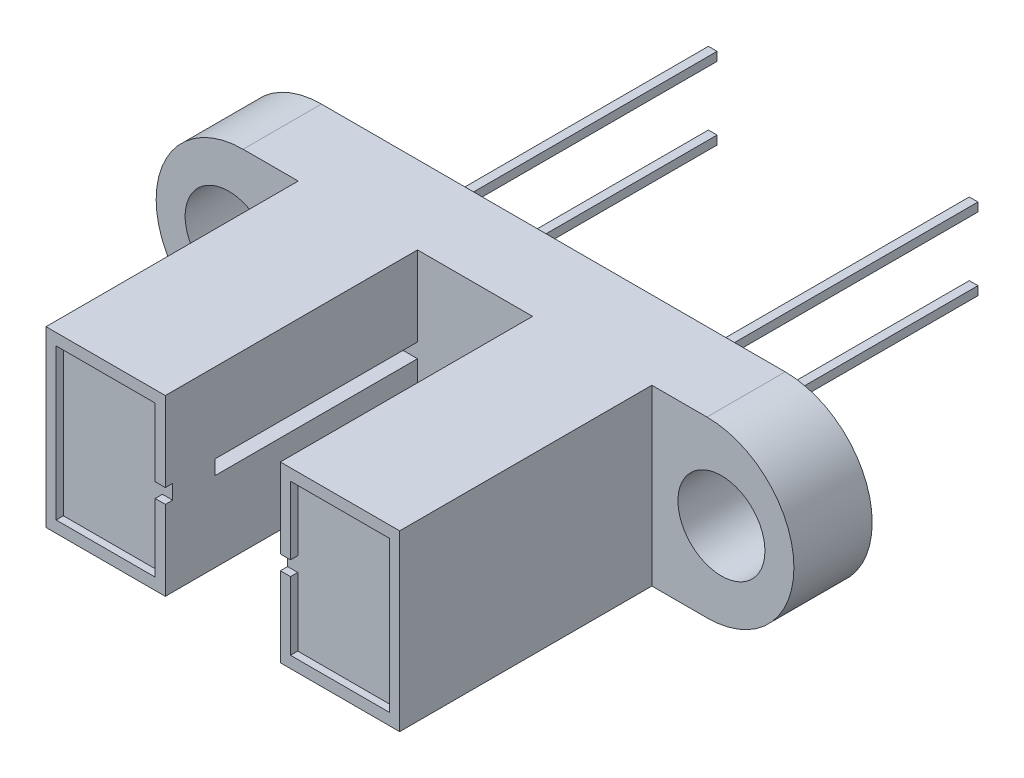
from build123d import *

# Parameters (mm, degrees)
BOSS_EXTRUDE1_DEPTH  = 2.7
SKETCH2_R            = 1.5
CUT_EXTRUDE1_DEPTH   = 3.7
SKETCH3_W            = 4.115625
SKETCH3_H            = 6
BOSS_EXTRUDE2_DEPTH  = 8.7
SKETCH4_W            = 12
SKETCH4_H            = 3
CUT_EXTRUDE2_DEPTH   = 2
CUT_EXTRUDE3_DEPTH   = 0.25
SKETCH6_W            = 0.3
SKETCH6_H            = 0.3
BOSS_EXTRUDE3_DEPTH  = 12
LPATTERN1_COUNT      = 2
LPATTERN1_PITCH      = 2.5
LPATTERN1_COUNT_DIR2 = 2
LPATTERN1_PITCH_DIR2 = 9
SKETCH7_W            = 6.98
SKETCH7_H            = 0.5
CUT_EXTRUDE4_DEPTH   = 1


with BuildPart() as part:
    # Sketch1 → Boss-Extrude1 (new body)
    with BuildSketch(Plane.XY):
        with BuildLine():
            Line((-8, 3), (8, 3))
            ThreePointArc((8, 3), (11, 0), (8, -3))
            Line((8, -3), (-8, -3))
            ThreePointArc((-8, -3), (-11, 0), (-8, 3))
        make_face()
    extrude(amount=BOSS_EXTRUDE1_DEPTH)

    # Sketch2 → Cut-Extrude1 (cut, through all)
    with BuildSketch(Plane.XY.offset(2.7)):
        with Locations((-8.5, 0)):
            Circle(SKETCH2_R)
        with Locations((8.5, 0)):
            Circle(SKETCH2_R)
    extrude(amount=-CUT_EXTRUDE1_DEPTH, mode=Mode.SUBTRACT)

    # Sketch3 → Boss-Extrude2 (add)
    with BuildSketch(Plane.XY.offset(2.7)):
        with Locations((-4.0421875, 0)):
            Rectangle(SKETCH3_W, SKETCH3_H)
        with Locations((4.0421875, 0)):
            Rectangle(SKETCH3_W, SKETCH3_H)
    extrude(amount=BOSS_EXTRUDE2_DEPTH)

    # Sketch4 → Cut-Extrude2 (cut)
    with BuildSketch(Plane(origin=(0, 0, 0), x_dir=(-1, 0, 0), z_dir=(0, 0, -1))):
        Rectangle(SKETCH4_W, SKETCH4_H)
    extrude(amount=-CUT_EXTRUDE2_DEPTH, mode=Mode.SUBTRACT)

    # Sketch5 → Cut-Extrude3 (cut)
    with BuildSketch(Plane.XY.offset(11.4)):
        Polygon((-2.334375, 0.25), (-1.984375, 0.25), (-1.984375, -0.25), (-2.334375, -0.25), (-2.334375, -2.6), (-5.75, -2.6), (-5.75, 2.6), (-2.334375, 2.6), align=None)
    cut_extrude3 = extrude(amount=-CUT_EXTRUDE3_DEPTH, mode=Mode.SUBTRACT)

    # Mirror1: Cut-Extrude3 across plane
    add(cut_extrude3.mirror(Plane(origin=(0, 0, 0), x_dir=(0, 0, 1), z_dir=(1, 0, 0))), mode=Mode.SUBTRACT)

    # Sketch6 → Boss-Extrude3 (add)
    with BuildSketch(Plane(origin=(0, 0, 2), x_dir=(-1, 0, 0), z_dir=(0, 0, -1))):
        with Locations((-4.5, 1.25)):
            Rectangle(SKETCH6_W, SKETCH6_H)
    boss_extrude3 = extrude(amount=BOSS_EXTRUDE3_DEPTH)

    # LPattern1: Boss-Extrude3 2 × 2
    with Locations(*[(-j * LPATTERN1_PITCH_DIR2, -i * LPATTERN1_PITCH, 0) for i in range(LPATTERN1_COUNT) for j in range(LPATTERN1_COUNT_DIR2) if (i, j) != (0, 0)]):
        add(boss_extrude3)

    # Sketch7 → Cut-Extrude4 (cut)
    with BuildSketch(Plane.ZY.offset(-1.984375)):
        with Locations((6.19, 0)):
            Rectangle(SKETCH7_W, SKETCH7_H)
    cut_extrude4 = extrude(amount=-CUT_EXTRUDE4_DEPTH, mode=Mode.SUBTRACT)

    # Mirror2: Cut-Extrude4 across plane
    add(cut_extrude4.mirror(Plane(origin=(0, 0, 0), x_dir=(0, 0, 1), z_dir=(1, 0, 0))), mode=Mode.SUBTRACT)


solid = part.part
